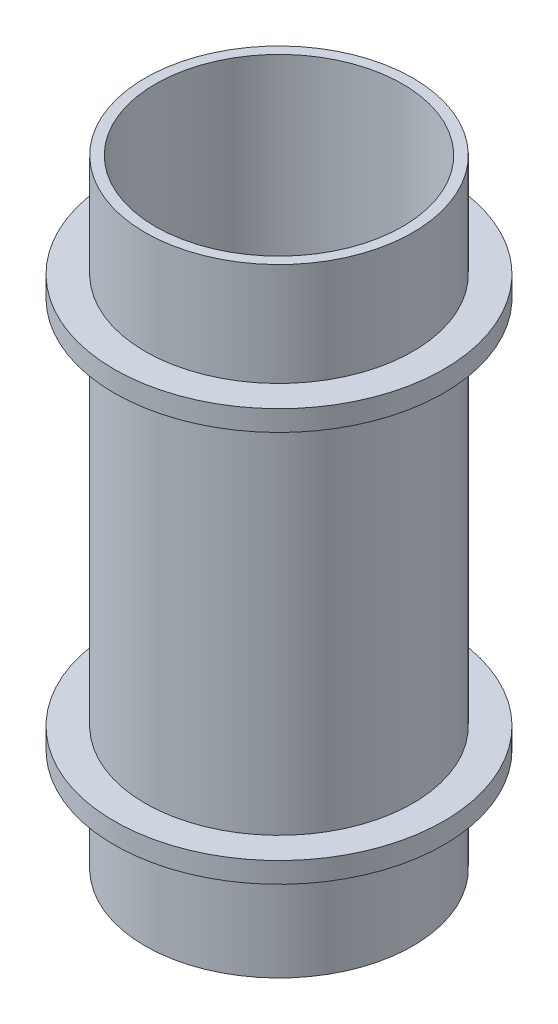
from build123d import *

# Parameters (mm, degrees)
SKETCH_1_R      = 13
SKETCH_1_R_2    = 12
EXTRUDE_1_DEPTH = 60
EXTRUDE_START   = -10
SKETCH_2_R      = 16
SKETCH_2_R_2    = 12
EXTRUDE_3_DEPTH = 2
SKETCH_3_R      = 16
SKETCH_3_R_2    = 12
EXTRUDE_4_DEPTH = 2


with BuildPart() as part:
    # Эскиз1 → Бобышка-Вытянуть1 (new body)
    with BuildSketch(Plane(origin=(0, 0, 0), x_dir=(1, 0, 0), z_dir=(0, 1, 0))):
        Circle(SKETCH_1_R)
        Circle(SKETCH_1_R_2, mode=Mode.SUBTRACT)
    extrude(amount=EXTRUDE_1_DEPTH)

    # Эскиз2 → Бобышка-Вытянуть3 (add)
    with BuildSketch(Plane(origin=(0, 60, 0), x_dir=(1, 0, 0), z_dir=(0, 1, 0)).offset(EXTRUDE_START)):
        Circle(SKETCH_2_R)
        Circle(SKETCH_2_R_2, mode=Mode.SUBTRACT)
    extrude(amount=-EXTRUDE_3_DEPTH)

    # Эскиз3 → Бобышка-Вытянуть4 (add)
    with BuildSketch(Plane.XZ.offset(EXTRUDE_START)):
        Circle(SKETCH_3_R)
        Circle(SKETCH_3_R_2, mode=Mode.SUBTRACT)
    extrude(amount=-EXTRUDE_4_DEPTH)


solid = part.part
